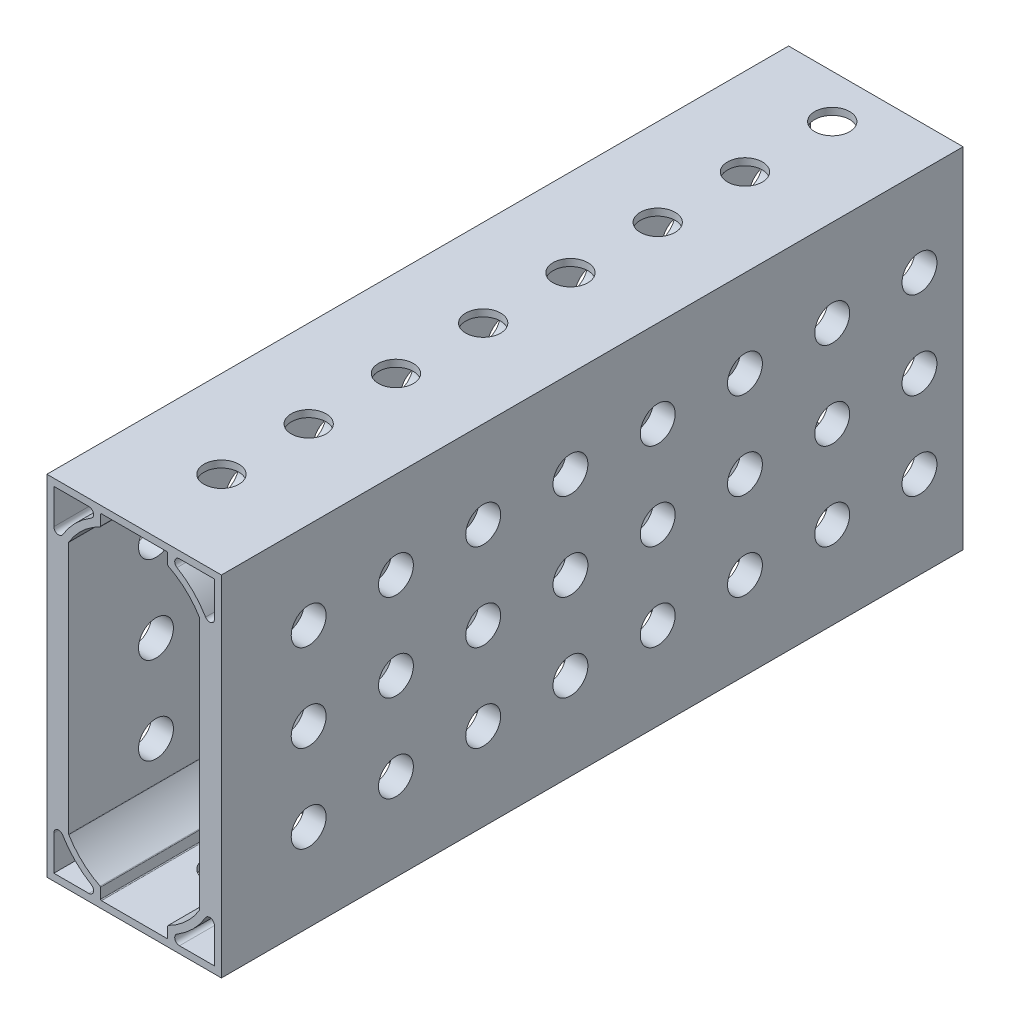
from build123d import *

# Parameters (mm, degrees)
SKETCH1_W                                = 50.8
SKETCH1_H                                = 107.95
BOSS_EXTRUDE1_DEPTH                      = 25.4
CUT_EXTRUDE9_DEPTH                       = 108.95
MIRROR1_AT_THE_SECOND_PLANE_COPY_1_DEPTH = 108.95
CUT_EXTRUDE11_START                      = -26.4
SKETCH17_R                               = 2.54
CUT_EXTRUDE11_DEPTH                      = 27.4
SKETCH18_R                               = 2.54
CUT_EXTRUDE12_DEPTH                      = 51.8
LPATTERN1_COUNT                          = 9
LPATTERN1_PITCH                          = 12.7
LPATTERN2_COUNT                          = 9
LPATTERN2_PITCH                          = 12.7
LPATTERN2_COUNT_DIR2                     = 3
LPATTERN2_PITCH_DIR2                     = 12.7
FILLET1_R                                = 0.127


with BuildPart() as part:
    # Sketch1 → Boss-Extrude1 (new body)
    with BuildSketch(Plane(origin=(-12.7, 0, 0), x_dir=(0, -1, 0), z_dir=(-1, 0, 0))):
        Rectangle(SKETCH1_W, SKETCH1_H)
    extrude(amount=-BOSS_EXTRUDE1_DEPTH)

    # Sketch10 → Cut-Extrude9 (cut, through all)
    with BuildSketch(Plane.XY.offset(53.975)):
        with BuildLine():
            Line((-11.684, 24.384), (-11.684, 19.297089026))
            ThreePointArc((-11.684, 19.297089026), (-11.177055919, 18.630604499), (-10.39941737, 18.941204261))
            ThreePointArc((-10.39941737, 18.941204261), (-8.576144596, 21.276144596), (-6.241204261, 23.09941737))
            ThreePointArc((-6.241204261, 23.09941737), (-5.930604499, 23.877055919), (-6.597089026, 24.384))
            Line((-6.597089026, 24.384), (-11.684, 24.384))
        make_face()
        with BuildLine():
            Line((0, 24.384), (-4.8895, 24.384))
            Line((-4.8895, 24.384), (-4.8895, 22.679000251))
            ThreePointArc((-4.8895, 22.679000251), (-7.514726072, 20.886363558), (-9.525, 18.42381265))
            Line((-9.525, 18.42381265), (-9.525, 0))
            Line((-9.525, 0), (0, 0))
            Line((0, 0), (0, 24.384))
        make_face()
    cut_extrude9 = extrude(amount=-CUT_EXTRUDE9_DEPTH, mode=Mode.SUBTRACT)

    # Mirror1: Cut-Extrude9 across plane
    add(cut_extrude9.mirror(Plane.ZX), mode=Mode.SUBTRACT)

    # Mirror1 at the second plane: Cut-Extrude9 across plane
    add(cut_extrude9.mirror(Plane(origin=(0, 0, 0), x_dir=(0, 0, 1), z_dir=(1, 0, 0))), mode=Mode.SUBTRACT)

    # Mirror1 at the second plane copy 1 sketc → Mirror1 at the second plane copy 1 (cut, through all)
    with BuildSketch(Plane(origin=(0, 0, 53.975), x_dir=(-1, 0, 0), z_dir=(0, 0, 1))):
        with BuildLine():
            Line((-11.684, 24.384), (-11.684, 19.297089026))
            ThreePointArc((-11.684, 19.297089026), (-11.177055919, 18.630604499), (-10.39941737, 18.941204261))
            ThreePointArc((-10.39941737, 18.941204261), (-8.576144596, 21.276144596), (-6.241204261, 23.09941737))
            ThreePointArc((-6.241204261, 23.09941737), (-5.930604499, 23.877055919), (-6.597089026, 24.384))
            Line((-6.597089026, 24.384), (-11.684, 24.384))
        make_face()
        with BuildLine():
            Line((0, 24.384), (-4.8895, 24.384))
            Line((-4.8895, 24.384), (-4.8895, 22.679000251))
            ThreePointArc((-4.8895, 22.679000251), (-7.514726072, 20.886363558), (-9.525, 18.42381265))
            Line((-9.525, 18.42381265), (-9.525, 0))
            Line((-9.525, 0), (0, 0))
            Line((0, 0), (0, 24.384))
        make_face()
    extrude(amount=-MIRROR1_AT_THE_SECOND_PLANE_COPY_1_DEPTH, mode=Mode.SUBTRACT)

    # Sketch17 → Cut-Extrude11 (cut)
    with BuildSketch(Plane(origin=(12.7, 0, 0), x_dir=(0, 0, -1), z_dir=(1, 0, 0)).offset(CUT_EXTRUDE11_START)):
        with Locations((-41.275, 12.7)):
            Circle(SKETCH17_R)
    cut_extrude11 = extrude(amount=CUT_EXTRUDE11_DEPTH, mode=Mode.SUBTRACT)

    # Sketch18 → Cut-Extrude12 (cut, through all)
    with BuildSketch(Plane(origin=(0, 25.4, 0), x_dir=(1, 0, 0), z_dir=(0, 1, 0))):
        with Locations((0, -41.275)):
            Circle(SKETCH18_R)
    cut_extrude12 = extrude(amount=-CUT_EXTRUDE12_DEPTH, mode=Mode.SUBTRACT)

    # LPattern1: Cut-Extrude12 ×9
    with Locations(*[(0, 0, -i * LPATTERN1_PITCH) for i in range(1, LPATTERN1_COUNT)]):
        add(cut_extrude12, mode=Mode.SUBTRACT)

    # LPattern2: Cut-Extrude11 9 × 3
    with Locations(*[(0, -j * LPATTERN2_PITCH_DIR2, -i * LPATTERN2_PITCH) for i in range(LPATTERN2_COUNT) for j in range(LPATTERN2_COUNT_DIR2) if (i, j) != (0, 0)]):
        add(cut_extrude11, mode=Mode.SUBTRACT)

    # Fillet1
    fillet1_edges = [part.edges().sort_by_distance(p)[0] for p in [
        (-4.8895, -24.384, 0),
        (-4.8895, -22.679000251, 0),
        (-9.525, -18.42381265, 0),
        (4.8895, -22.679000251, 0),
        (4.8895, -24.384, 0),
        (9.525, -18.42381265, 0),
        (-4.8895, 22.679000251, 0),
        (-4.8895, 24.384, 0),
        (-9.525, 18.42381265, 0),
        (4.8895, 24.384, 0),
        (4.8895, 22.679000251, 0),
        (9.525, 18.42381265, 0),
    ]]
    fillet(fillet1_edges, radius=FILLET1_R)


solid = part.part
